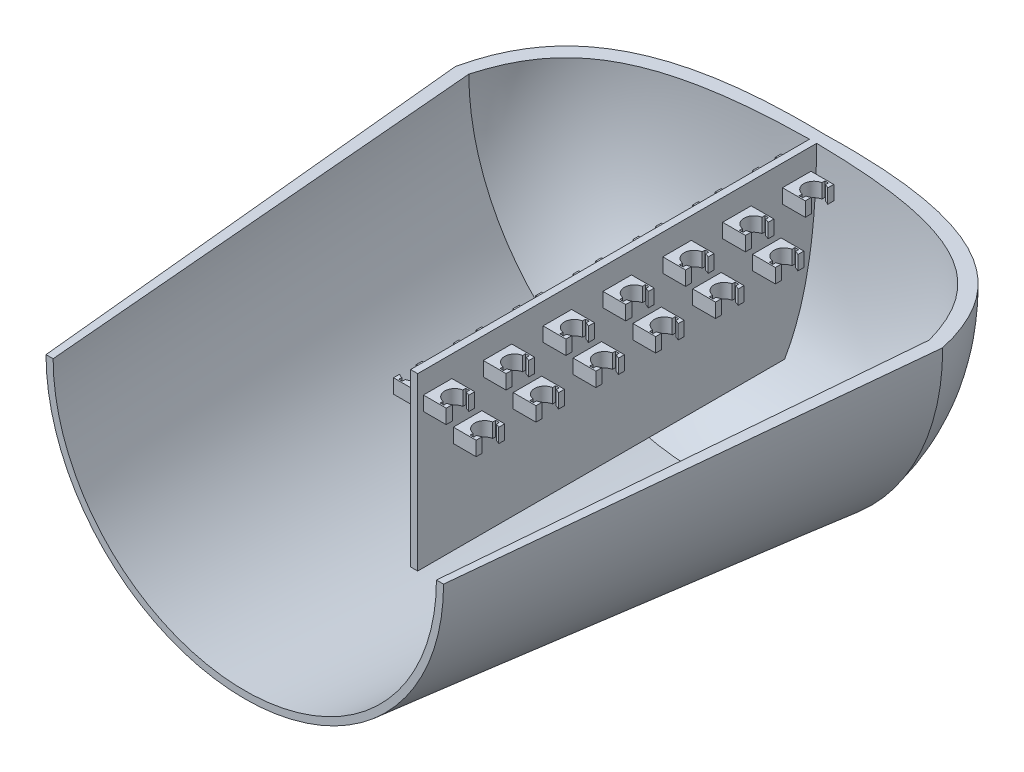
from build123d import *

# Parameters (mm, degrees)
SKETCH1_W                = 3.175
SKETCH1_H                = 177.8
BOSS_EXTRUDE1_DEPTH      = 76.2
SKETCH2_W                = 12.7
SKETCH2_H                = 6.35
BOSS_EXTRUDE2_DEPTH      = 10.16
CUT_EXTRUDE1_DEPTH       = 6.35
LPATTERN2_COUNT          = 7
LPATTERN2_PITCH          = 26.67
SKETCH4_W                = 12.7
SKETCH4_H                = 6.35
BOSS_EXTRUDE3_DEPTH      = 10.16
SKETCH5_R                = 4.445
SKETCH5_W                = 1.5875
SKETCH5_H                = 11.43
CUT_EXTRUDE2_DEPTH       = 6.35
LPATTERN3_COUNT          = 6
LPATTERN3_PITCH          = 26.67
MIRROR1_COPY_1_SKETCH_W  = 12.7
MIRROR1_COPY_1_SKETCH_H  = 6.35
MIRROR1_COPY_1_DEPTH     = 10.16
MIRROR1_COPY_2_SKETCH_W  = 12.7
MIRROR1_COPY_2_SKETCH_H  = 6.35
MIRROR1_COPY_2_DEPTH     = 10.16
MIRROR1_COPY_3_SKETCH_W  = 12.7
MIRROR1_COPY_3_SKETCH_H  = 6.35
MIRROR1_COPY_3_DEPTH     = 10.16
MIRROR1_COPY_4_SKETCH_W  = 12.7
MIRROR1_COPY_4_SKETCH_H  = 6.35
MIRROR1_COPY_4_DEPTH     = 10.16
MIRROR1_COPY_5_SKETCH_W  = 12.7
MIRROR1_COPY_5_SKETCH_H  = 6.35
MIRROR1_COPY_5_DEPTH     = 10.16
MIRROR1_COPY_6_SKETCH_W  = 12.7
MIRROR1_COPY_6_SKETCH_H  = 6.35
MIRROR1_COPY_6_DEPTH     = 10.16
MIRROR1_COPY_7_DEPTH     = 6.35
MIRROR1_COPY_8_DEPTH     = 6.35
MIRROR1_COPY_9_DEPTH     = 6.35
MIRROR1_COPY_10_DEPTH    = 6.35
MIRROR1_COPY_11_DEPTH    = 6.35
MIRROR1_COPY_12_DEPTH    = 6.35
MIRROR1_COPY_13_SKETCH_W = 12.7
MIRROR1_COPY_13_SKETCH_H = 6.35
MIRROR1_COPY_13_DEPTH    = 10.16
MIRROR1_COPY_14_SKETCH_W = 12.7
MIRROR1_COPY_14_SKETCH_H = 6.35
MIRROR1_COPY_14_DEPTH    = 10.16
MIRROR1_COPY_15_SKETCH_W = 12.7
MIRROR1_COPY_15_SKETCH_H = 6.35
MIRROR1_COPY_15_DEPTH    = 10.16
MIRROR1_COPY_16_SKETCH_W = 12.7
MIRROR1_COPY_16_SKETCH_H = 6.35
MIRROR1_COPY_16_DEPTH    = 10.16
MIRROR1_COPY_17_SKETCH_W = 12.7
MIRROR1_COPY_17_SKETCH_H = 6.35
MIRROR1_COPY_17_DEPTH    = 10.16
MIRROR1_COPY_18_SKETCH_R = 4.445
MIRROR1_COPY_18_SKETCH_W = 1.5875
MIRROR1_COPY_18_SKETCH_H = 11.43
MIRROR1_COPY_18_DEPTH    = 6.35
MIRROR1_COPY_19_SKETCH_R = 4.445
MIRROR1_COPY_19_SKETCH_W = 1.5875
MIRROR1_COPY_19_SKETCH_H = 11.43
MIRROR1_COPY_19_DEPTH    = 6.35
MIRROR1_COPY_20_SKETCH_R = 4.445
MIRROR1_COPY_20_SKETCH_W = 1.5875
MIRROR1_COPY_20_SKETCH_H = 11.43
MIRROR1_COPY_20_DEPTH    = 6.35
MIRROR1_COPY_21_SKETCH_R = 4.445
MIRROR1_COPY_21_SKETCH_W = 1.5875
MIRROR1_COPY_21_SKETCH_H = 11.43
MIRROR1_COPY_21_DEPTH    = 6.35
MIRROR1_COPY_22_SKETCH_R = 4.445
MIRROR1_COPY_22_SKETCH_W = 1.5875
MIRROR1_COPY_22_SKETCH_H = 11.43
MIRROR1_COPY_22_DEPTH    = 6.35
REVOLVE2_ANGLE           = 180


with BuildPart() as part:
    # Sketch1 → Boss-Extrude1 (new body)
    with BuildSketch(Plane(origin=(0, 0, 0), x_dir=(1, 0, 0), z_dir=(0, 1, 0))):
        Rectangle(SKETCH1_W, SKETCH1_H)
    extrude(amount=BOSS_EXTRUDE1_DEPTH)

    # Sketch2 → Boss-Extrude2 (add)
    with BuildSketch(Plane(origin=(1.5875, 0, 0), x_dir=(0, 0, -1), z_dir=(1, 0, 0))):
        with Locations((80.01, 63.5)):
            Rectangle(SKETCH2_W, SKETCH2_H)
    boss_extrude2 = extrude(amount=BOSS_EXTRUDE2_DEPTH)

    # Sketch3 → Cut-Extrude1 (cut)
    with BuildSketch(Plane(origin=(0, 66.675, 0), x_dir=(1, 0, 0), z_dir=(0, 1, 0))):
        with BuildLine():
            ThreePointArc((8.41375, 84.383555297), (4.7625, 80.01), (8.41375, 75.636444703))
            Line((8.41375, 75.636444703), (8.41375, 84.383555297))
        make_face()
        with BuildLine():
            Line((8.41375, 75.636444703), (8.41375, 74.295))
            Line((8.41375, 74.295), (10.00125, 74.295))
            Line((10.00125, 74.295), (10.00125, 75.636444703))
            ThreePointArc((10.00125, 75.636444703), (9.2075, 75.565), (8.41375, 75.636444703))
        make_face()
        with BuildLine():
            Line((8.41375, 84.383555297), (8.41375, 75.636444703))
            ThreePointArc((8.41375, 75.636444703), (9.2075, 75.565), (10.00125, 75.636444703))
            Line((10.00125, 75.636444703), (10.00125, 84.383555297))
            ThreePointArc((10.00125, 84.383555297), (9.2075, 84.455), (8.41375, 84.383555297))
        make_face()
        with BuildLine():
            Line((8.41375, 85.725), (8.41375, 84.383555297))
            ThreePointArc((8.41375, 84.383555297), (9.2075, 84.455), (10.00125, 84.383555297))
            Line((10.00125, 84.383555297), (10.00125, 85.725))
            Line((10.00125, 85.725), (8.41375, 85.725))
        make_face()
        with BuildLine():
            Line((10.00125, 84.383555297), (10.00125, 75.636444703))
            ThreePointArc((10.00125, 75.636444703), (10.913417184, 75.905384115), (11.7475, 76.362202719))
            Line((11.7475, 76.362202719), (11.7475, 83.657797281))
            ThreePointArc((11.7475, 83.657797281), (10.913417184, 84.114615885), (10.00125, 84.383555297))
        make_face()
    cut_extrude1 = extrude(amount=-CUT_EXTRUDE1_DEPTH, mode=Mode.SUBTRACT)

    # LPattern2: Boss-Extrude2, Cut-Extrude1 ×7
    with Locations(*[(0, 0, i * LPATTERN2_PITCH) for i in range(1, LPATTERN2_COUNT)]):
        add(boss_extrude2)
        add(cut_extrude1, mode=Mode.SUBTRACT)

    # Sketch4 → Boss-Extrude3 (add)
    with BuildSketch(Plane(origin=(1.5875, 0, 0), x_dir=(0, 0, -1), z_dir=(1, 0, 0))):
        with Locations((66.675, 44.45)):
            Rectangle(SKETCH4_W, SKETCH4_H)
    boss_extrude3 = extrude(amount=BOSS_EXTRUDE3_DEPTH)

    # Sketch5 → Cut-Extrude2 (cut)
    with BuildSketch(Plane(origin=(0, 47.625, 0), x_dir=(1, 0, 0), z_dir=(0, 1, 0))):
        with Locations((9.2075, 66.675)):
            Circle(SKETCH5_R)
        with Locations((9.2075, 66.675)):
            Rectangle(SKETCH5_W, SKETCH5_H)
    cut_extrude2 = extrude(amount=-CUT_EXTRUDE2_DEPTH, mode=Mode.SUBTRACT)

    # LPattern3: Boss-Extrude3, Cut-Extrude2 ×6
    with Locations(*[(0, 0, i * LPATTERN3_PITCH) for i in range(1, LPATTERN3_COUNT)]):
        add(boss_extrude3)
        add(cut_extrude2, mode=Mode.SUBTRACT)

    # Mirror1: Boss-Extrude2, Cut-Extrude1, Boss-Extrude3, Cut-Extrude2 across plane
    add(boss_extrude2.mirror(Plane(origin=(0, 0, 0), x_dir=(0, 0, 1), z_dir=(1, 0, 0))))
    add(cut_extrude1.mirror(Plane(origin=(0, 0, 0), x_dir=(0, 0, 1), z_dir=(1, 0, 0))), mode=Mode.SUBTRACT)
    add(boss_extrude3.mirror(Plane(origin=(0, 0, 0), x_dir=(0, 0, 1), z_dir=(1, 0, 0))))
    add(cut_extrude2.mirror(Plane(origin=(0, 0, 0), x_dir=(0, 0, 1), z_dir=(1, 0, 0))), mode=Mode.SUBTRACT)

    # Mirror1 copy 1 sketch → Mirror1 copy 1 (add)
    with BuildSketch(Plane(origin=(-1.5875, 0, 26.67), x_dir=(0, 0, -1), z_dir=(-1, 0, 0))):
        with Locations((80.01, -63.5)):
            Rectangle(MIRROR1_COPY_1_SKETCH_W, MIRROR1_COPY_1_SKETCH_H)
    extrude(amount=MIRROR1_COPY_1_DEPTH)

    # Mirror1 copy 2 sketch → Mirror1 copy 2 (add)
    with BuildSketch(Plane(origin=(-1.5875, 0, 53.34), x_dir=(0, 0, -1), z_dir=(-1, 0, 0))):
        with Locations((80.01, -63.5)):
            Rectangle(MIRROR1_COPY_2_SKETCH_W, MIRROR1_COPY_2_SKETCH_H)
    extrude(amount=MIRROR1_COPY_2_DEPTH)

    # Mirror1 copy 3 sketch → Mirror1 copy 3 (add)
    with BuildSketch(Plane(origin=(-1.5875, 0, 80.01), x_dir=(0, 0, -1), z_dir=(-1, 0, 0))):
        with Locations((80.01, -63.5)):
            Rectangle(MIRROR1_COPY_3_SKETCH_W, MIRROR1_COPY_3_SKETCH_H)
    extrude(amount=MIRROR1_COPY_3_DEPTH)

    # Mirror1 copy 4 sketch → Mirror1 copy 4 (add)
    with BuildSketch(Plane(origin=(-1.5875, 0, 106.68), x_dir=(0, 0, -1), z_dir=(-1, 0, 0))):
        with Locations((80.01, -63.5)):
            Rectangle(MIRROR1_COPY_4_SKETCH_W, MIRROR1_COPY_4_SKETCH_H)
    extrude(amount=MIRROR1_COPY_4_DEPTH)

    # Mirror1 copy 5 sketch → Mirror1 copy 5 (add)
    with BuildSketch(Plane(origin=(-1.5875, 0, 133.35), x_dir=(0, 0, -1), z_dir=(-1, 0, 0))):
        with Locations((80.01, -63.5)):
            Rectangle(MIRROR1_COPY_5_SKETCH_W, MIRROR1_COPY_5_SKETCH_H)
    extrude(amount=MIRROR1_COPY_5_DEPTH)

    # Mirror1 copy 6 sketch → Mirror1 copy 6 (add)
    with BuildSketch(Plane(origin=(-1.5875, 0, 160.02), x_dir=(0, 0, -1), z_dir=(-1, 0, 0))):
        with Locations((80.01, -63.5)):
            Rectangle(MIRROR1_COPY_6_SKETCH_W, MIRROR1_COPY_6_SKETCH_H)
    extrude(amount=MIRROR1_COPY_6_DEPTH)

    # Mirror1 copy 7 sketch → Mirror1 copy 7 (cut)
    with BuildSketch(Plane(origin=(0, 66.675, 26.67), x_dir=(-1, 0, 0), z_dir=(0, 1, 0))):
        with BuildLine():
            ThreePointArc((8.41375, -84.383555297), (4.7625, -80.01), (8.41375, -75.636444703))
            Line((8.41375, -75.636444703), (8.41375, -84.383555297))
        make_face()
        with BuildLine():
            Line((8.41375, -75.636444703), (8.41375, -74.295))
            Line((8.41375, -74.295), (10.00125, -74.295))
            Line((10.00125, -74.295), (10.00125, -75.636444703))
            ThreePointArc((10.00125, -75.636444703), (9.2075, -75.565), (8.41375, -75.636444703))
        make_face()
        with BuildLine():
            Line((8.41375, -84.383555297), (8.41375, -75.636444703))
            ThreePointArc((8.41375, -75.636444703), (9.2075, -75.565), (10.00125, -75.636444703))
            Line((10.00125, -75.636444703), (10.00125, -84.383555297))
            ThreePointArc((10.00125, -84.383555297), (9.2075, -84.455), (8.41375, -84.383555297))
        make_face()
        with BuildLine():
            Line((8.41375, -85.725), (8.41375, -84.383555297))
            ThreePointArc((8.41375, -84.383555297), (9.2075, -84.455), (10.00125, -84.383555297))
            Line((10.00125, -84.383555297), (10.00125, -85.725))
            Line((10.00125, -85.725), (8.41375, -85.725))
        make_face()
        with BuildLine():
            Line((10.00125, -84.383555297), (10.00125, -75.636444703))
            ThreePointArc((10.00125, -75.636444703), (10.913417184, -75.905384115), (11.7475, -76.362202719))
            Line((11.7475, -76.362202719), (11.7475, -83.657797281))
            ThreePointArc((11.7475, -83.657797281), (10.913417184, -84.114615885), (10.00125, -84.383555297))
        make_face()
    extrude(amount=-MIRROR1_COPY_7_DEPTH, mode=Mode.SUBTRACT)

    # Mirror1 copy 8 sketch → Mirror1 copy 8 (cut)
    with BuildSketch(Plane(origin=(0, 66.675, 53.34), x_dir=(-1, 0, 0), z_dir=(0, 1, 0))):
        with BuildLine():
            ThreePointArc((8.41375, -84.383555297), (4.7625, -80.01), (8.41375, -75.636444703))
            Line((8.41375, -75.636444703), (8.41375, -84.383555297))
        make_face()
        with BuildLine():
            Line((8.41375, -75.636444703), (8.41375, -74.295))
            Line((8.41375, -74.295), (10.00125, -74.295))
            Line((10.00125, -74.295), (10.00125, -75.636444703))
            ThreePointArc((10.00125, -75.636444703), (9.2075, -75.565), (8.41375, -75.636444703))
        make_face()
        with BuildLine():
            Line((8.41375, -84.383555297), (8.41375, -75.636444703))
            ThreePointArc((8.41375, -75.636444703), (9.2075, -75.565), (10.00125, -75.636444703))
            Line((10.00125, -75.636444703), (10.00125, -84.383555297))
            ThreePointArc((10.00125, -84.383555297), (9.2075, -84.455), (8.41375, -84.383555297))
        make_face()
        with BuildLine():
            Line((8.41375, -85.725), (8.41375, -84.383555297))
            ThreePointArc((8.41375, -84.383555297), (9.2075, -84.455), (10.00125, -84.383555297))
            Line((10.00125, -84.383555297), (10.00125, -85.725))
            Line((10.00125, -85.725), (8.41375, -85.725))
        make_face()
        with BuildLine():
            Line((10.00125, -84.383555297), (10.00125, -75.636444703))
            ThreePointArc((10.00125, -75.636444703), (10.913417184, -75.905384115), (11.7475, -76.362202719))
            Line((11.7475, -76.362202719), (11.7475, -83.657797281))
            ThreePointArc((11.7475, -83.657797281), (10.913417184, -84.114615885), (10.00125, -84.383555297))
        make_face()
    extrude(amount=-MIRROR1_COPY_8_DEPTH, mode=Mode.SUBTRACT)

    # Mirror1 copy 9 sketch → Mirror1 copy 9 (cut)
    with BuildSketch(Plane(origin=(0, 66.675, 80.01), x_dir=(-1, 0, 0), z_dir=(0, 1, 0))):
        with BuildLine():
            ThreePointArc((8.41375, -84.383555297), (4.7625, -80.01), (8.41375, -75.636444703))
            Line((8.41375, -75.636444703), (8.41375, -84.383555297))
        make_face()
        with BuildLine():
            Line((8.41375, -75.636444703), (8.41375, -74.295))
            Line((8.41375, -74.295), (10.00125, -74.295))
            Line((10.00125, -74.295), (10.00125, -75.636444703))
            ThreePointArc((10.00125, -75.636444703), (9.2075, -75.565), (8.41375, -75.636444703))
        make_face()
        with BuildLine():
            Line((8.41375, -84.383555297), (8.41375, -75.636444703))
            ThreePointArc((8.41375, -75.636444703), (9.2075, -75.565), (10.00125, -75.636444703))
            Line((10.00125, -75.636444703), (10.00125, -84.383555297))
            ThreePointArc((10.00125, -84.383555297), (9.2075, -84.455), (8.41375, -84.383555297))
        make_face()
        with BuildLine():
            Line((8.41375, -85.725), (8.41375, -84.383555297))
            ThreePointArc((8.41375, -84.383555297), (9.2075, -84.455), (10.00125, -84.383555297))
            Line((10.00125, -84.383555297), (10.00125, -85.725))
            Line((10.00125, -85.725), (8.41375, -85.725))
        make_face()
        with BuildLine():
            Line((10.00125, -84.383555297), (10.00125, -75.636444703))
            ThreePointArc((10.00125, -75.636444703), (10.913417184, -75.905384115), (11.7475, -76.362202719))
            Line((11.7475, -76.362202719), (11.7475, -83.657797281))
            ThreePointArc((11.7475, -83.657797281), (10.913417184, -84.114615885), (10.00125, -84.383555297))
        make_face()
    extrude(amount=-MIRROR1_COPY_9_DEPTH, mode=Mode.SUBTRACT)

    # Mirror1 copy 10 sketch → Mirror1 copy 10 (cut)
    with BuildSketch(Plane(origin=(0, 66.675, 106.68), x_dir=(-1, 0, 0), z_dir=(0, 1, 0))):
        with BuildLine():
            ThreePointArc((8.41375, -84.383555297), (4.7625, -80.01), (8.41375, -75.636444703))
            Line((8.41375, -75.636444703), (8.41375, -84.383555297))
        make_face()
        with BuildLine():
            Line((8.41375, -75.636444703), (8.41375, -74.295))
            Line((8.41375, -74.295), (10.00125, -74.295))
            Line((10.00125, -74.295), (10.00125, -75.636444703))
            ThreePointArc((10.00125, -75.636444703), (9.2075, -75.565), (8.41375, -75.636444703))
        make_face()
        with BuildLine():
            Line((8.41375, -84.383555297), (8.41375, -75.636444703))
            ThreePointArc((8.41375, -75.636444703), (9.2075, -75.565), (10.00125, -75.636444703))
            Line((10.00125, -75.636444703), (10.00125, -84.383555297))
            ThreePointArc((10.00125, -84.383555297), (9.2075, -84.455), (8.41375, -84.383555297))
        make_face()
        with BuildLine():
            Line((8.41375, -85.725), (8.41375, -84.383555297))
            ThreePointArc((8.41375, -84.383555297), (9.2075, -84.455), (10.00125, -84.383555297))
            Line((10.00125, -84.383555297), (10.00125, -85.725))
            Line((10.00125, -85.725), (8.41375, -85.725))
        make_face()
        with BuildLine():
            Line((10.00125, -84.383555297), (10.00125, -75.636444703))
            ThreePointArc((10.00125, -75.636444703), (10.913417184, -75.905384115), (11.7475, -76.362202719))
            Line((11.7475, -76.362202719), (11.7475, -83.657797281))
            ThreePointArc((11.7475, -83.657797281), (10.913417184, -84.114615885), (10.00125, -84.383555297))
        make_face()
    extrude(amount=-MIRROR1_COPY_10_DEPTH, mode=Mode.SUBTRACT)

    # Mirror1 copy 11 sketch → Mirror1 copy 11 (cut)
    with BuildSketch(Plane(origin=(0, 66.675, 133.35), x_dir=(-1, 0, 0), z_dir=(0, 1, 0))):
        with BuildLine():
            ThreePointArc((8.41375, -84.383555297), (4.7625, -80.01), (8.41375, -75.636444703))
            Line((8.41375, -75.636444703), (8.41375, -84.383555297))
        make_face()
        with BuildLine():
            Line((8.41375, -75.636444703), (8.41375, -74.295))
            Line((8.41375, -74.295), (10.00125, -74.295))
            Line((10.00125, -74.295), (10.00125, -75.636444703))
            ThreePointArc((10.00125, -75.636444703), (9.2075, -75.565), (8.41375, -75.636444703))
        make_face()
        with BuildLine():
            Line((8.41375, -84.383555297), (8.41375, -75.636444703))
            ThreePointArc((8.41375, -75.636444703), (9.2075, -75.565), (10.00125, -75.636444703))
            Line((10.00125, -75.636444703), (10.00125, -84.383555297))
            ThreePointArc((10.00125, -84.383555297), (9.2075, -84.455), (8.41375, -84.383555297))
        make_face()
        with BuildLine():
            Line((8.41375, -85.725), (8.41375, -84.383555297))
            ThreePointArc((8.41375, -84.383555297), (9.2075, -84.455), (10.00125, -84.383555297))
            Line((10.00125, -84.383555297), (10.00125, -85.725))
            Line((10.00125, -85.725), (8.41375, -85.725))
        make_face()
        with BuildLine():
            Line((10.00125, -84.383555297), (10.00125, -75.636444703))
            ThreePointArc((10.00125, -75.636444703), (10.913417184, -75.905384115), (11.7475, -76.362202719))
            Line((11.7475, -76.362202719), (11.7475, -83.657797281))
            ThreePointArc((11.7475, -83.657797281), (10.913417184, -84.114615885), (10.00125, -84.383555297))
        make_face()
    extrude(amount=-MIRROR1_COPY_11_DEPTH, mode=Mode.SUBTRACT)

    # Mirror1 copy 12 sketch → Mirror1 copy 12 (cut)
    with BuildSketch(Plane(origin=(0, 66.675, 160.02), x_dir=(-1, 0, 0), z_dir=(0, 1, 0))):
        with BuildLine():
            ThreePointArc((8.41375, -84.383555297), (4.7625, -80.01), (8.41375, -75.636444703))
            Line((8.41375, -75.636444703), (8.41375, -84.383555297))
        make_face()
        with BuildLine():
            Line((8.41375, -75.636444703), (8.41375, -74.295))
            Line((8.41375, -74.295), (10.00125, -74.295))
            Line((10.00125, -74.295), (10.00125, -75.636444703))
            ThreePointArc((10.00125, -75.636444703), (9.2075, -75.565), (8.41375, -75.636444703))
        make_face()
        with BuildLine():
            Line((8.41375, -84.383555297), (8.41375, -75.636444703))
            ThreePointArc((8.41375, -75.636444703), (9.2075, -75.565), (10.00125, -75.636444703))
            Line((10.00125, -75.636444703), (10.00125, -84.383555297))
            ThreePointArc((10.00125, -84.383555297), (9.2075, -84.455), (8.41375, -84.383555297))
        make_face()
        with BuildLine():
            Line((8.41375, -85.725), (8.41375, -84.383555297))
            ThreePointArc((8.41375, -84.383555297), (9.2075, -84.455), (10.00125, -84.383555297))
            Line((10.00125, -84.383555297), (10.00125, -85.725))
            Line((10.00125, -85.725), (8.41375, -85.725))
        make_face()
        with BuildLine():
            Line((10.00125, -84.383555297), (10.00125, -75.636444703))
            ThreePointArc((10.00125, -75.636444703), (10.913417184, -75.905384115), (11.7475, -76.362202719))
            Line((11.7475, -76.362202719), (11.7475, -83.657797281))
            ThreePointArc((11.7475, -83.657797281), (10.913417184, -84.114615885), (10.00125, -84.383555297))
        make_face()
    extrude(amount=-MIRROR1_COPY_12_DEPTH, mode=Mode.SUBTRACT)

    # Mirror1 copy 13 sketch → Mirror1 copy 13 (add)
    with BuildSketch(Plane(origin=(-1.5875, 0, 26.67), x_dir=(0, 0, -1), z_dir=(-1, 0, 0))):
        with Locations((66.675, -44.45)):
            Rectangle(MIRROR1_COPY_13_SKETCH_W, MIRROR1_COPY_13_SKETCH_H)
    extrude(amount=MIRROR1_COPY_13_DEPTH)

    # Mirror1 copy 14 sketch → Mirror1 copy 14 (add)
    with BuildSketch(Plane(origin=(-1.5875, 0, 53.34), x_dir=(0, 0, -1), z_dir=(-1, 0, 0))):
        with Locations((66.675, -44.45)):
            Rectangle(MIRROR1_COPY_14_SKETCH_W, MIRROR1_COPY_14_SKETCH_H)
    extrude(amount=MIRROR1_COPY_14_DEPTH)

    # Mirror1 copy 15 sketch → Mirror1 copy 15 (add)
    with BuildSketch(Plane(origin=(-1.5875, 0, 80.01), x_dir=(0, 0, -1), z_dir=(-1, 0, 0))):
        with Locations((66.675, -44.45)):
            Rectangle(MIRROR1_COPY_15_SKETCH_W, MIRROR1_COPY_15_SKETCH_H)
    extrude(amount=MIRROR1_COPY_15_DEPTH)

    # Mirror1 copy 16 sketch → Mirror1 copy 16 (add)
    with BuildSketch(Plane(origin=(-1.5875, 0, 106.68), x_dir=(0, 0, -1), z_dir=(-1, 0, 0))):
        with Locations((66.675, -44.45)):
            Rectangle(MIRROR1_COPY_16_SKETCH_W, MIRROR1_COPY_16_SKETCH_H)
    extrude(amount=MIRROR1_COPY_16_DEPTH)

    # Mirror1 copy 17 sketch → Mirror1 copy 17 (add)
    with BuildSketch(Plane(origin=(-1.5875, 0, 133.35), x_dir=(0, 0, -1), z_dir=(-1, 0, 0))):
        with Locations((66.675, -44.45)):
            Rectangle(MIRROR1_COPY_17_SKETCH_W, MIRROR1_COPY_17_SKETCH_H)
    extrude(amount=MIRROR1_COPY_17_DEPTH)

    # Mirror1 copy 18 sketch → Mirror1 copy 18 (cut)
    with BuildSketch(Plane(origin=(0, 47.625, 26.67), x_dir=(-1, 0, 0), z_dir=(0, 1, 0))):
        with Locations((9.2075, -66.675)):
            Circle(MIRROR1_COPY_18_SKETCH_R)
        with Locations((9.2075, -66.675)):
            Rectangle(MIRROR1_COPY_18_SKETCH_W, MIRROR1_COPY_18_SKETCH_H)
    extrude(amount=-MIRROR1_COPY_18_DEPTH, mode=Mode.SUBTRACT)

    # Mirror1 copy 19 sketch → Mirror1 copy 19 (cut)
    with BuildSketch(Plane(origin=(0, 47.625, 53.34), x_dir=(-1, 0, 0), z_dir=(0, 1, 0))):
        with Locations((9.2075, -66.675)):
            Circle(MIRROR1_COPY_19_SKETCH_R)
        with Locations((9.2075, -66.675)):
            Rectangle(MIRROR1_COPY_19_SKETCH_W, MIRROR1_COPY_19_SKETCH_H)
    extrude(amount=-MIRROR1_COPY_19_DEPTH, mode=Mode.SUBTRACT)

    # Mirror1 copy 20 sketch → Mirror1 copy 20 (cut)
    with BuildSketch(Plane(origin=(0, 47.625, 80.01), x_dir=(-1, 0, 0), z_dir=(0, 1, 0))):
        with Locations((9.2075, -66.675)):
            Circle(MIRROR1_COPY_20_SKETCH_R)
        with Locations((9.2075, -66.675)):
            Rectangle(MIRROR1_COPY_20_SKETCH_W, MIRROR1_COPY_20_SKETCH_H)
    extrude(amount=-MIRROR1_COPY_20_DEPTH, mode=Mode.SUBTRACT)

    # Mirror1 copy 21 sketch → Mirror1 copy 21 (cut)
    with BuildSketch(Plane(origin=(0, 47.625, 106.68), x_dir=(-1, 0, 0), z_dir=(0, 1, 0))):
        with Locations((9.2075, -66.675)):
            Circle(MIRROR1_COPY_21_SKETCH_R)
        with Locations((9.2075, -66.675)):
            Rectangle(MIRROR1_COPY_21_SKETCH_W, MIRROR1_COPY_21_SKETCH_H)
    extrude(amount=-MIRROR1_COPY_21_DEPTH, mode=Mode.SUBTRACT)

    # Mirror1 copy 22 sketch → Mirror1 copy 22 (cut)
    with BuildSketch(Plane(origin=(0, 47.625, 133.35), x_dir=(-1, 0, 0), z_dir=(0, 1, 0))):
        with Locations((9.2075, -66.675)):
            Circle(MIRROR1_COPY_22_SKETCH_R)
        with Locations((9.2075, -66.675)):
            Rectangle(MIRROR1_COPY_22_SKETCH_W, MIRROR1_COPY_22_SKETCH_H)
    extrude(amount=-MIRROR1_COPY_22_DEPTH, mode=Mode.SUBTRACT)

    # Sketch8 → Revolve2 (revolve)
    with BuildSketch(Plane(origin=(0, 76.2, 0), x_dir=(1, 0, 0), z_dir=(0, 1, 0))):
        with BuildLine():
            Line((0, 88.9), (0, 94.096733273))
            add(Edge.make_bspline(
                [(0, 94.096733273), (73.356435095, 96.018644468), (100.307506237, 74.806936641), (108.580235195, 38.079904804)],
                knots=[0, 0, 0, 0, 1, 1, 1, 1], degree=3))
            Line((108.580235195, 38.079904804), (88.589782285, -164.389957491))
            Line((88.589782285, -164.389957491), (85.414782285, -164.389957491))
            Line((85.414782285, -164.389957491), (102.625074662, 38.079906529))
            add(Edge.make_bspline(
                [(0, 88.9), (69.200872257, 88.289726963), (93.115030307, 72.10883442), (102.625074662, 38.079906529)],
                knots=[0, 0, 0, 0, 1, 1, 1, 1], degree=3))
        make_face()
    revolve(axis=Axis((0, 76.2, 98.526148991), (0, 0, -1)), revolution_arc=REVOLVE2_ANGLE)


solid = part.part
